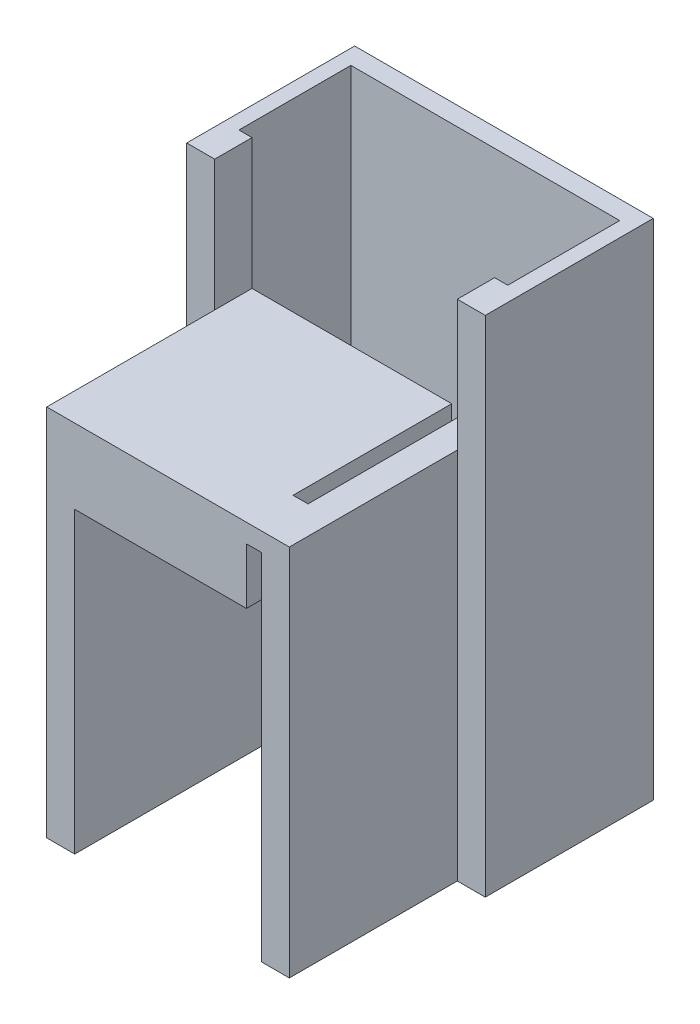
from build123d import *

# Parameters (mm, degrees)
BOSS_EXTRUDE1_DEPTH      = 13.97
SKETCH3_W                = 1.016
SKETCH3_H                = 3.81
CUT_EXTRUDE1_DEPTH       = 14.97
CUT_EXTRUDE2_DEPTH       = 2.27
BOSS_EXTRUDE3_DEPTH      = 8.89
BOSS_EXTRUDE3_DEPTH_BACK = 25.4
SKETCH12_W               = 18.294327288
SKETCH12_H               = 7.62
BOSS_EXTRUDE4_DEPTH      = 1.27


with BuildPart() as part:
    # Sketch1 → Boss-Extrude1 (new body)
    with BuildSketch(Plane.XY):
        Polygon((0, 0), (0, 20.32), (-12.7, 20.32), (-12.7, 0), (-14.605, 0), (-14.605, 25.4), (1.905, 25.4), (1.905, 0), align=None)
    extrude(amount=-BOSS_EXTRUDE1_DEPTH)

    # Sketch3 → Cut-Extrude1 (cut, through all)
    with BuildSketch(Plane.XY):
        with Locations((-0.508, 22.225)):
            Rectangle(SKETCH3_W, SKETCH3_H)
    extrude(amount=-CUT_EXTRUDE1_DEPTH, mode=Mode.SUBTRACT)

    # Sketch4 → Cut-Extrude2 (cut, through all)
    with BuildSketch(Plane.XZ.offset(-24.13)):
        Polygon((-1.016, -6.985), (-1.016, -3.175), (0, -3.175), (0, -13.97), (-1.016, -13.97), align=None)
    extrude(amount=-CUT_EXTRUDE2_DEPTH, mode=Mode.SUBTRACT)

    # Sketch11 → Boss-Extrude3 (add, two sides)
    with BuildSketch(Plane(origin=(0, 25.4, 0), x_dir=(1, 0, 0), z_dir=(0, 1, 0))) as boss_extrude3_sk:
        Polygon((-15.497163644, 13.97), (-14.605, 13.97), (-14.605, 11.43), (-16.51, 11.43), (-16.51, 22.86), (3.81, 22.86), (3.81, 11.43), (1.905, 11.43), (1.905, 13.97), (2.797163644, 13.97), (2.797163644, 21.59), (-15.497163644, 21.59), align=None)
    extrude(amount=BOSS_EXTRUDE3_DEPTH)
    extrude(boss_extrude3_sk.sketch, amount=-BOSS_EXTRUDE3_DEPTH_BACK)

    # Sketch12 → Boss-Extrude4 (add)
    with BuildSketch(Plane.XZ):
        with Locations((-6.35, -17.78)):
            Rectangle(SKETCH12_W, SKETCH12_H)
    extrude(amount=-BOSS_EXTRUDE4_DEPTH)


solid = part.part
